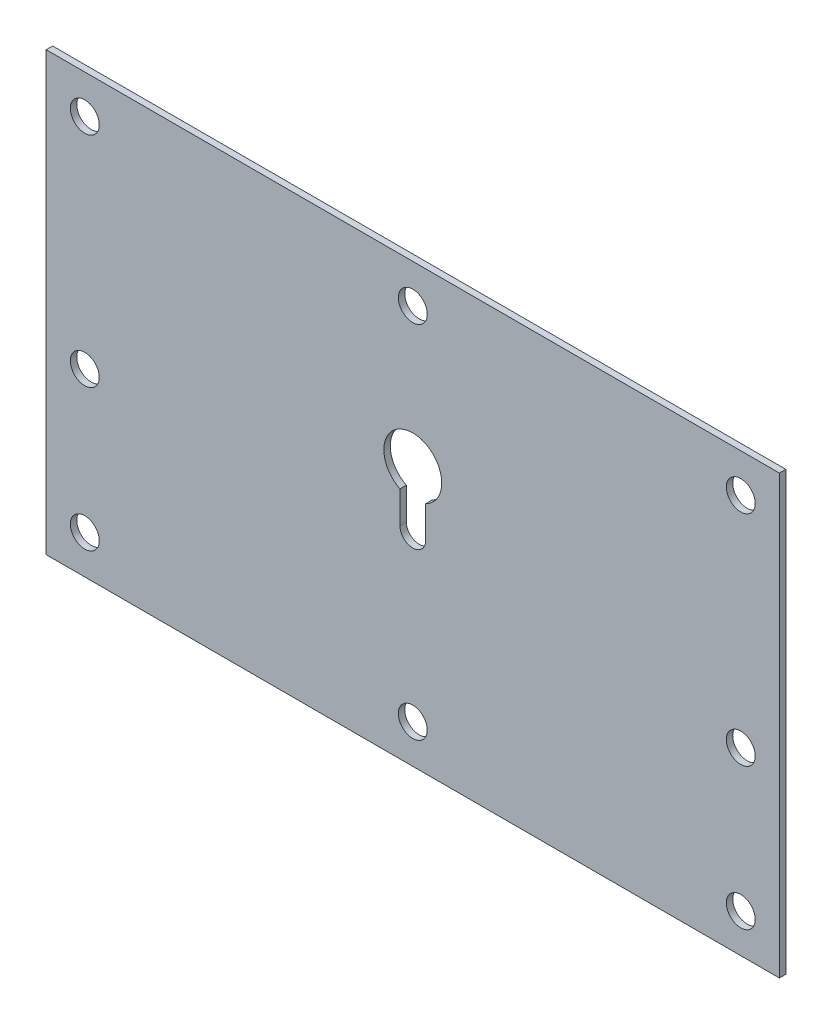
from build123d import *

# Parameters (mm, degrees)
SKETCH_1_W          = 114
SKETCH_1_H          = 68
EXTRUDE_1_DEPTH     = 1
CUT_EXTRUDE_1_REACH = 3
SKETCH_2_R          = 2.25


with BuildPart() as part:
    # Эскиз1 → Бобышка-Вытянуть1 (new body)
    with BuildSketch(Plane.XY):
        with Locations((57, 34)):
            Rectangle(SKETCH_1_W, SKETCH_1_H)
    extrude(amount=EXTRUDE_1_DEPTH)

    # Эскиз2 → Вырез-Вытянуть1 (cut, up to next)
    with BuildSketch(Plane.XY.offset(1), mode=Mode.PRIVATE) as cut_extrude_1_sk1:
        with Locations((6, 62)):
            Circle(SKETCH_2_R)
    cut_extrude_1_tool1 = extrude(cut_extrude_1_sk1.sketch, amount=-CUT_EXTRUDE_1_REACH, mode=Mode.PRIVATE) & part.part
    add(cut_extrude_1_tool1.solids().sort_by_distance((6, 62, 1))[0], mode=Mode.SUBTRACT)
    # Эскиз2 → Вырез-Вытянуть1 (cut, up to next)
    with BuildSketch(Plane.XY.offset(1), mode=Mode.PRIVATE) as cut_extrude_1_sk2:
        with Locations((6, 28)):
            Circle(SKETCH_2_R)
    cut_extrude_1_tool2 = extrude(cut_extrude_1_sk2.sketch, amount=-CUT_EXTRUDE_1_REACH, mode=Mode.PRIVATE) & part.part
    add(cut_extrude_1_tool2.solids().sort_by_distance((6, 28, 1))[0], mode=Mode.SUBTRACT)
    # Эскиз2 → Вырез-Вытянуть1 (cut, up to next)
    with BuildSketch(Plane.XY.offset(1), mode=Mode.PRIVATE) as cut_extrude_1_sk3:
        with Locations((6, 6)):
            Circle(SKETCH_2_R)
    cut_extrude_1_tool3 = extrude(cut_extrude_1_sk3.sketch, amount=-CUT_EXTRUDE_1_REACH, mode=Mode.PRIVATE) & part.part
    add(cut_extrude_1_tool3.solids().sort_by_distance((6, 6, 1))[0], mode=Mode.SUBTRACT)
    # Эскиз2 → Вырез-Вытянуть1 (cut, up to next)
    with BuildSketch(Plane.XY.offset(1), mode=Mode.PRIVATE) as cut_extrude_1_sk4:
        with Locations((57, 6)):
            Circle(SKETCH_2_R)
    cut_extrude_1_tool4 = extrude(cut_extrude_1_sk4.sketch, amount=-CUT_EXTRUDE_1_REACH, mode=Mode.PRIVATE) & part.part
    add(cut_extrude_1_tool4.solids().sort_by_distance((57, 6, 1))[0], mode=Mode.SUBTRACT)
    # Эскиз2 → Вырез-Вытянуть1 (cut, up to next)
    with BuildSketch(Plane.XY.offset(1), mode=Mode.PRIVATE) as cut_extrude_1_sk5:
        with Locations((57, 62)):
            Circle(SKETCH_2_R)
    cut_extrude_1_tool5 = extrude(cut_extrude_1_sk5.sketch, amount=-CUT_EXTRUDE_1_REACH, mode=Mode.PRIVATE) & part.part
    add(cut_extrude_1_tool5.solids().sort_by_distance((57, 62, 1))[0], mode=Mode.SUBTRACT)
    # Эскиз2 → Вырез-Вытянуть1 (cut, up to next)
    with BuildSketch(Plane.XY.offset(1), mode=Mode.PRIVATE) as cut_extrude_1_sk6:
        with Locations((108, 62)):
            Circle(SKETCH_2_R)
    cut_extrude_1_tool6 = extrude(cut_extrude_1_sk6.sketch, amount=-CUT_EXTRUDE_1_REACH, mode=Mode.PRIVATE) & part.part
    add(cut_extrude_1_tool6.solids().sort_by_distance((108, 62, 1))[0], mode=Mode.SUBTRACT)
    # Эскиз2 → Вырез-Вытянуть1 (cut, up to next)
    with BuildSketch(Plane.XY.offset(1), mode=Mode.PRIVATE) as cut_extrude_1_sk7:
        with Locations((108, 28)):
            Circle(SKETCH_2_R)
    cut_extrude_1_tool7 = extrude(cut_extrude_1_sk7.sketch, amount=-CUT_EXTRUDE_1_REACH, mode=Mode.PRIVATE) & part.part
    add(cut_extrude_1_tool7.solids().sort_by_distance((108, 28, 1))[0], mode=Mode.SUBTRACT)
    # Эскиз2 → Вырез-Вытянуть1 (cut, up to next)
    with BuildSketch(Plane.XY.offset(1), mode=Mode.PRIVATE) as cut_extrude_1_sk8:
        with Locations((108, 6)):
            Circle(SKETCH_2_R)
    cut_extrude_1_tool8 = extrude(cut_extrude_1_sk8.sketch, amount=-CUT_EXTRUDE_1_REACH, mode=Mode.PRIVATE) & part.part
    add(cut_extrude_1_tool8.solids().sort_by_distance((108, 6, 1))[0], mode=Mode.SUBTRACT)
    # Эскиз2 → Вырез-Вытянуть1 (cut, up to next)
    with BuildSketch(Plane.XY.offset(1), mode=Mode.PRIVATE) as cut_extrude_1_sk9:
        with BuildLine():
            Line((59, 36.368871126), (59, 31.4))
            ThreePointArc((59, 31.4), (57, 29.4), (55, 31.4))
            Line((55, 31.4), (55, 36.368871126))
            ThreePointArc((55, 36.368871126), (57, 44.9), (59, 36.368871126))
        make_face()
    cut_extrude_1_tool9 = extrude(cut_extrude_1_sk9.sketch, amount=-CUT_EXTRUDE_1_REACH, mode=Mode.PRIVATE) & part.part
    add(cut_extrude_1_tool9.solids().sort_by_distance((57, 38.298039, 1))[0], mode=Mode.SUBTRACT)


solid = part.part
